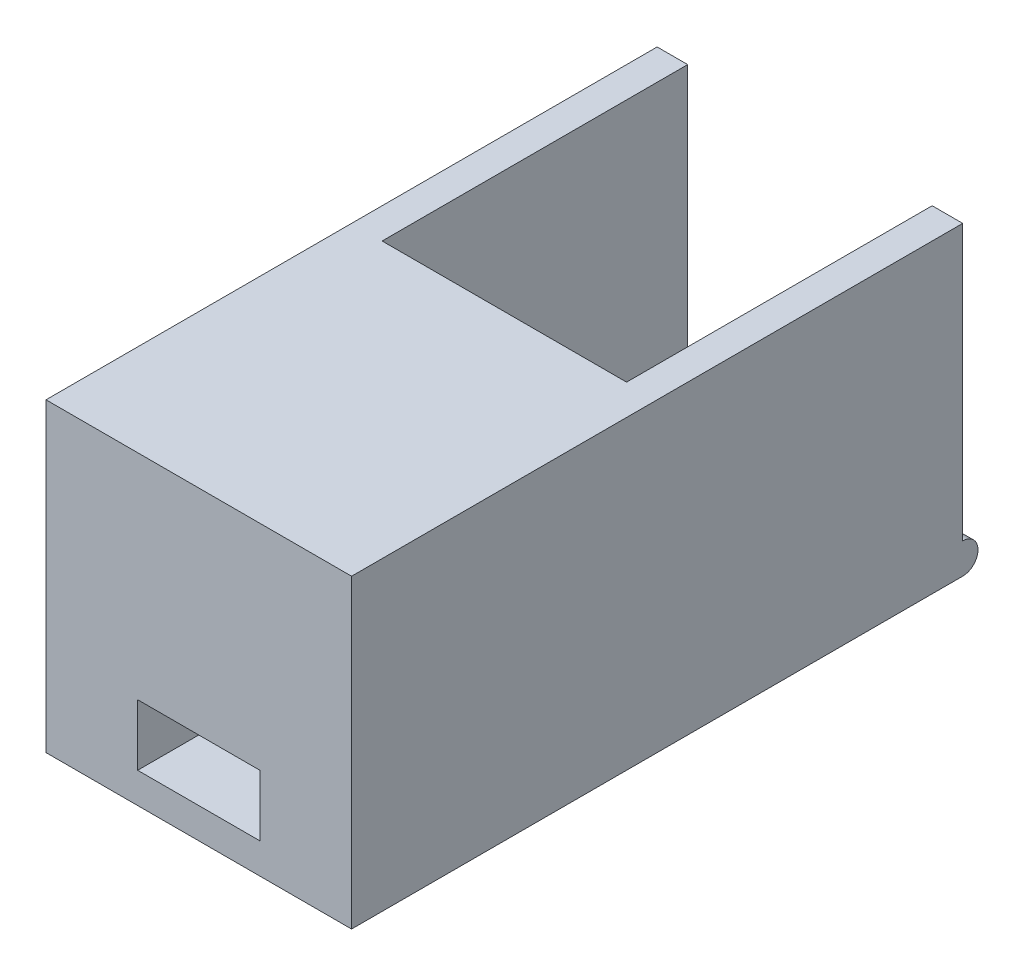
from build123d import *

# Parameters (mm, degrees)
SKETCH_1_W          = 20
SKETCH_1_H          = 40
EXTRUDE_1_DEPTH     = 20
SKETCH_2_W          = 16
SKETCH_2_H          = 20
CUT_EXTRUDE_1_DEPTH = 18
SKETCH_3_W          = 8
SKETCH_3_H          = 38.402735184
CUT_EXTRUDE_2_DEPTH = 20
SKETCH_4_R          = 1
EXTRUDE_2_DEPTH     = 6
SKETCH_5_R          = 1
EXTRUDE_3_DEPTH     = 6
SKETCH_6_W          = 8
SKETCH_6_H          = 4
CUT_EXTRUDE_3_DEPTH = 30


with BuildPart() as part:
    # 草图1 → 凸台-拉伸1 (new body)
    with BuildSketch(Plane(origin=(0, 0, 0), x_dir=(1, 0, 0), z_dir=(0, 1, 0))):
        Rectangle(SKETCH_1_W, SKETCH_1_H)
    extrude(amount=EXTRUDE_1_DEPTH)

    # 草图2 → 切除-拉伸1 (cut)
    with BuildSketch(Plane(origin=(0, 20, 0), x_dir=(1, 0, 0), z_dir=(0, 1, 0))):
        with Locations((0, 10)):
            Rectangle(SKETCH_2_W, SKETCH_2_H)
    extrude(amount=-CUT_EXTRUDE_1_DEPTH, mode=Mode.SUBTRACT)

    # 草图3 → 切除-拉伸2 (cut)
    with BuildSketch(Plane.XZ):
        with Locations((0, -23.201367592)):
            Rectangle(SKETCH_3_W, SKETCH_3_H)
    extrude(amount=-CUT_EXTRUDE_2_DEPTH, mode=Mode.SUBTRACT)

    # 草图4 → 凸台-拉伸2 (add)
    with BuildSketch(Plane(origin=(-4, 0, 0), x_dir=(0, 0, -1), z_dir=(1, 0, 0))):
        with Locations((20, 1)):
            Circle(SKETCH_4_R)
    extrude(amount=-EXTRUDE_2_DEPTH)

    # 草图5 → 凸台-拉伸3 (add)
    with BuildSketch(Plane.ZY.offset(-4)):
        with Locations((-20, 1)):
            Circle(SKETCH_5_R)
    extrude(amount=-EXTRUDE_3_DEPTH)

    # 草图6 → 切除-拉伸3 (cut)
    with BuildSketch(Plane(origin=(0, 0, 0), x_dir=(-1, 0, 0), z_dir=(0, 0, -1))):
        with Locations((0, 4)):
            Rectangle(SKETCH_6_W, SKETCH_6_H)
    extrude(amount=-CUT_EXTRUDE_3_DEPTH, mode=Mode.SUBTRACT)


solid = part.part
